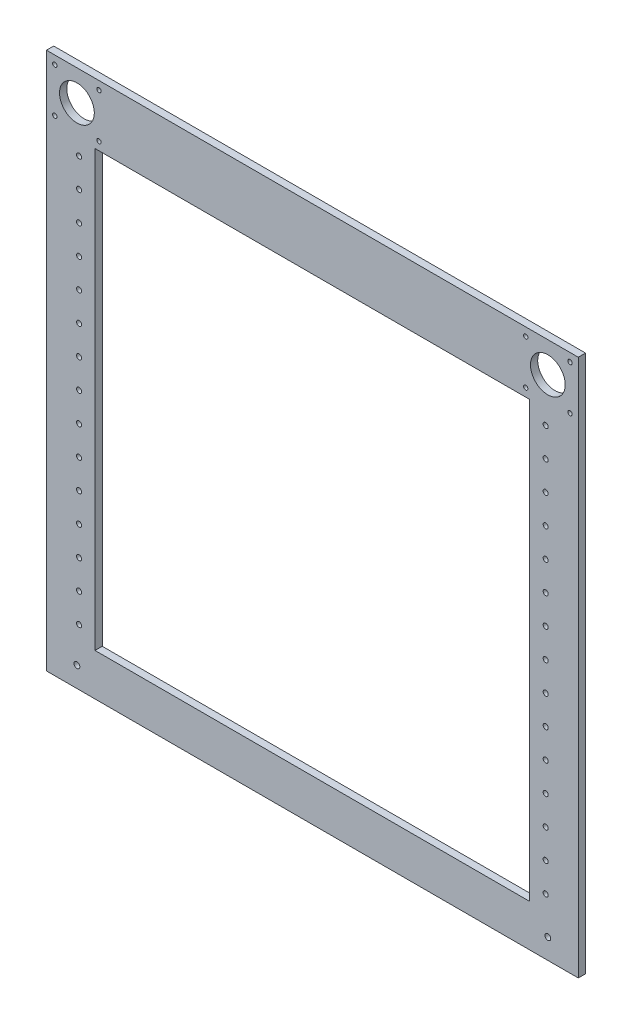
from build123d import *

# Parameters (mm, degrees)
SKETCH2_W           = 347
SKETCH2_H           = 371
SKETCH2_W_2         = 300
SKETCH2_H_2         = 300
BOSS_EXTRUDE1_DEPTH = 5
SKETCH6_R           = 1.75
CUT_EXTRUDE1_DEPTH  = 10
SKETCH7_W           = 10
SKETCH7_H           = 371
BOSS_EXTRUDE2_DEPTH = 5
SKETCH3_R           = 12
CUT_EXTRUDE2_DEPTH  = 5
SKETCH9_R           = 1.5
CUT_EXTRUDE3_DEPTH  = 6
SKETCH10_R          = 2
CUT_EXTRUDE4_DEPTH  = 5


with BuildPart() as part:
    # Sketch2 → Boss-Extrude1 (new body)
    with BuildSketch(Plane.XY.offset(-4)):
        with Locations((-157.5, -343.5)):
            Rectangle(SKETCH2_W, SKETCH2_H)
        with Locations((-157.5, -350)):
            Rectangle(SKETCH2_W_2, SKETCH2_H_2, mode=Mode.SUBTRACT)
    extrude(amount=BOSS_EXTRUDE1_DEPTH)

    # Sketch6 → Cut-Extrude1 (cut)
    with BuildSketch(Plane(origin=(0, 0, -4), x_dir=(-1, 0, 0), z_dir=(0, 0, -1))):
        with Locations((318.499999962, -490)):
            Circle(SKETCH6_R)
        with Locations((318.499999962, -470)):
            Circle(SKETCH6_R)
        with Locations((318.499999962, -450)):
            Circle(SKETCH6_R)
        with Locations((318.499999962, -430)):
            Circle(SKETCH6_R)
        with Locations((318.499999962, -410)):
            Circle(SKETCH6_R)
        with Locations((318.499999962, -390)):
            Circle(SKETCH6_R)
        with Locations((318.499999962, -370)):
            Circle(SKETCH6_R)
        with Locations((318.499999962, -350)):
            Circle(SKETCH6_R)
        with Locations((318.499999962, -330)):
            Circle(SKETCH6_R)
        with Locations((318.499999962, -310)):
            Circle(SKETCH6_R)
        with Locations((318.499999962, -290)):
            Circle(SKETCH6_R)
        with Locations((318.499999962, -270)):
            Circle(SKETCH6_R)
        with Locations((318.499999962, -250)):
            Circle(SKETCH6_R)
        with Locations((318.499999962, -230)):
            Circle(SKETCH6_R)
        with Locations((318.499999962, -210)):
            Circle(SKETCH6_R)
    cut_extrude1 = extrude(amount=-CUT_EXTRUDE1_DEPTH, mode=Mode.SUBTRACT)

    # Mirror1: Cut-Extrude1 across plane
    add(cut_extrude1.mirror(Plane.ZY.offset(157.5)), mode=Mode.SUBTRACT)

    # Sketch7 → Boss-Extrude2 (add)
    with BuildSketch(Plane.XY.offset(1)):
        with Locations((-336, -343.5)):
            Rectangle(SKETCH7_W, SKETCH7_H)
    boss_extrude2 = extrude(amount=-BOSS_EXTRUDE2_DEPTH)

    # Mirror2: Boss-Extrude2 across plane
    add(boss_extrude2.mirror(Plane.ZY.offset(157.5)))

    # Sketch3 → Cut-Extrude2 (cut)
    with BuildSketch(Plane(origin=(0, 0, -4), x_dir=(-1, 0, 0), z_dir=(0, 0, -1))):
        with Locations((319.999999962, -179)):
            Circle(SKETCH3_R)
    cut_extrude2 = extrude(amount=-CUT_EXTRUDE2_DEPTH, mode=Mode.SUBTRACT)

    # Sketch9 → Cut-Extrude3 (cut, through all)
    with BuildSketch(Plane(origin=(0, 0, -4), x_dir=(-1, 0, 0), z_dir=(0, 0, -1))):
        with Locations((335.266435368, -194.266435406)):
            Circle(SKETCH9_R)
        with Locations((335.266435368, -163.733564594)):
            Circle(SKETCH9_R)
        with Locations((304.733564556, -163.733564594)):
            Circle(SKETCH9_R)
        with Locations((304.733564556, -194.266435406)):
            Circle(SKETCH9_R)
    cut_extrude3 = extrude(amount=-CUT_EXTRUDE3_DEPTH, mode=Mode.SUBTRACT)

    # Mirror3: Cut-Extrude2, Cut-Extrude3 across plane
    add(cut_extrude2.mirror(Plane.ZY.offset(157.5)), mode=Mode.SUBTRACT)
    add(cut_extrude3.mirror(Plane.ZY.offset(157.5)), mode=Mode.SUBTRACT)

    # Sketch10 → Cut-Extrude4 (cut)
    with BuildSketch(Plane.XY.offset(1)):
        with Locations((-319.999999962, -515)):
            Circle(SKETCH10_R)
    cut_extrude4 = extrude(amount=-CUT_EXTRUDE4_DEPTH, mode=Mode.SUBTRACT)

    # Mirror4: Cut-Extrude4 across plane
    add(cut_extrude4.mirror(Plane.ZY.offset(157.5)), mode=Mode.SUBTRACT)


solid = part.part
